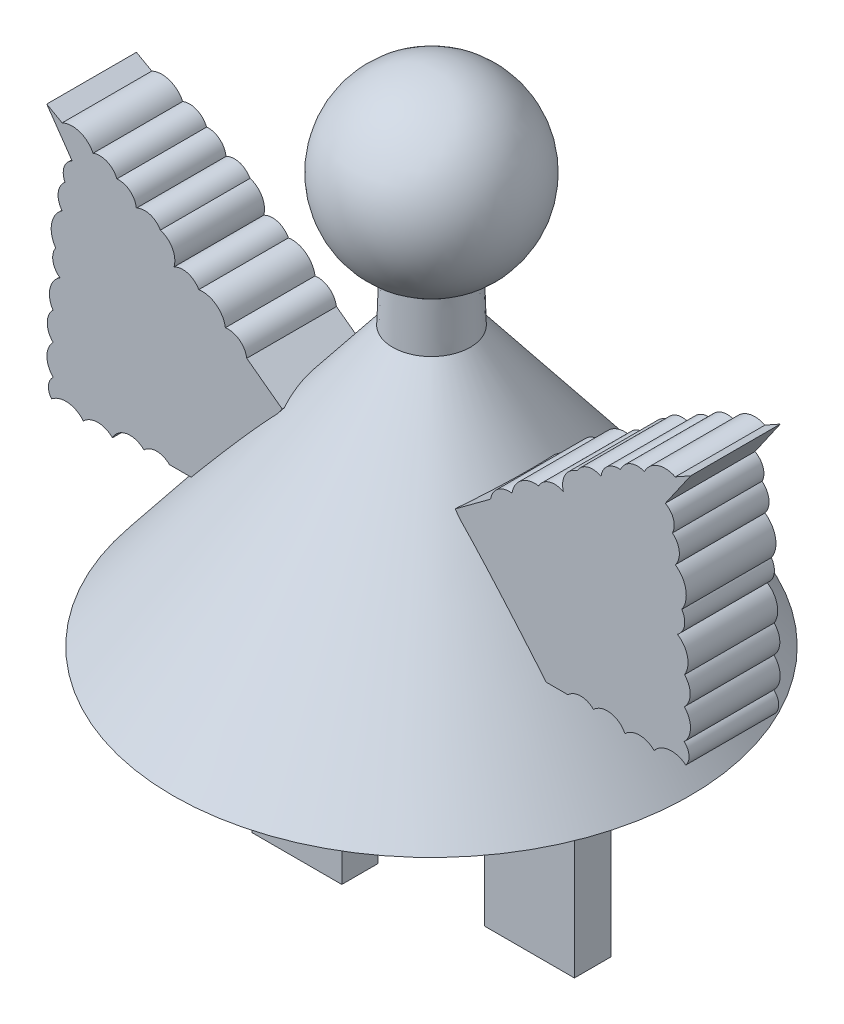
from build123d import *

# Parameters (mm, degrees)
SKETCH2_W           = 12.7
SKETCH2_H           = 5.158072601
BOSS_EXTRUDE1_DEPTH = 30.48
BOSS_EXTRUDE2_DEPTH = 6.35


with BuildPart() as part:
    # Sketch1 → Revolve1 (revolve)
    with BuildSketch(Plane.XY, mode=Mode.PRIVATE) as revolve1_sk:
        with BuildLine():
            Line((5.497877947, -31.389690294), (5.282120164, -24.249424513))
            ThreePointArc((5.282120164, -24.249424513), (12.409022752, -9.99701011), (0, 0))
            Line((0, 0), (0, -70.812800241))
            Line((0, -70.812800241), (36.63136247, -70.812800241))
            Line((36.63136247, -70.812800241), (5.497877947, -31.389690294))
        make_face()
    revolve(revolve1_sk.sketch.rotate(Axis((0, 0, 0), (0, -1, 0)), 90), axis=Axis((0, 0, 0), (0, -1, 0)))  # turned: the seam where the file's is

    # Sketch2 → Boss-Extrude1 (add)
    with BuildSketch(Plane(origin=(0, -70.812800241, 0), x_dir=(-1, 0, 0), z_dir=(0, -1, 0))):
        with Locations((13.97, -2.5009637)):
            Rectangle(SKETCH2_W, SKETCH2_H)
        with Locations((-13.97, 2.5009637)):
            Rectangle(SKETCH2_W, SKETCH2_H)
    extrude(amount=BOSS_EXTRUDE1_DEPTH)

    # Sketch4 → Boss-Extrude2 (add, symmetric)
    with BuildSketch(Plane.XY.offset(2.54)):
        with BuildLine():
            Line((23.194397658, -58.195407075), (28.218678504, -58.195407075))
            ThreePointArc((28.218678504, -58.195407075), (30.027441839, -57.44619277), (31.836205173, -58.195407075))
            ThreePointArc((31.836205173, -58.195407075), (34.251957858, -57.421245639), (36.286043383, -58.937056657))
            ThreePointArc((36.286043383, -58.937056657), (38.347997753, -58.082967192), (40.409952123, -58.937056657))
            ThreePointArc((40.409952123, -58.937056657), (42.564346856, -57.773722125), (44.910335716, -58.474507515))
            ThreePointArc((44.910335716, -58.474507515), (45.361627038, -57.049665796), (44.673222951, -55.723039401))
            ThreePointArc((44.673222951, -55.723039401), (45.573759248, -53.584134002), (44.698100059, -51.434924167))
            ThreePointArc((44.698100059, -51.434924167), (45.526766993, -49.466398887), (44.720765428, -47.488485304))
            ThreePointArc((44.720765428, -47.488485304), (45.146776163, -45.049852477), (43.723637436, -43.024243586))
            ThreePointArc((43.723637436, -43.024243586), (44.720765428, -41.476171224), (44.331188928, -39.676442795))
            ThreePointArc((44.331188928, -39.676442795), (44.916218335, -36.976008484), (43.420401182, -34.652834811))
            ThreePointArc((43.420401182, -34.652834811), (43.980987953, -32.721408857), (43.01165827, -30.959289761))
            ThreePointArc((43.01165827, -30.959289761), (43.155496077, -29.184392296), (42.002162733, -27.827641575))
            Line((42.002162733, -27.827641575), (45.598003191, -22.653559314))
            Line((45.598003191, -22.653559314), (43.420401182, -23.871865995))
            ThreePointArc((43.420401182, -23.871865995), (40.913084014, -23.73552357), (39.043734388, -25.41205589))
            ThreePointArc((39.043734388, -25.41205589), (37.052487537, -25.435932109), (35.661346423, -26.860839296))
            ThreePointArc((35.661346423, -26.860839296), (33.825367945, -27.399752632), (32.908204388, -29.079054738))
            ThreePointArc((32.908204388, -29.079054738), (31.003426578, -28.874097378), (29.511618532, -30.076051946))
            ThreePointArc((29.511618532, -30.076051946), (27.807974314, -31.448683603), (27.573913087, -33.623939136))
            ThreePointArc((27.573913087, -33.623939136), (25.608192785, -33.412424259), (24.068655026, -34.652834811))
            ThreePointArc((24.068655026, -34.652834811), (21.607314855, -35.264896302), (20.299677359, -37.438119458))
            ThreePointArc((20.299677359, -37.438119458), (18.321683781, -37.929987145), (17.270834086, -39.676442795))
            Line((17.270834086, -39.676442795), (12.250540769, -43.386453078))
            Line((12.250540769, -43.386453078), (23.194397658, -58.195407075))
        make_face()
        with BuildLine():
            Line((-23.194397658, -58.195407075), (-28.218678504, -58.195407075))
            ThreePointArc((-28.218678504, -58.195407075), (-30.027441839, -57.44619277), (-31.836205173, -58.195407075))
            ThreePointArc((-31.836205173, -58.195407075), (-34.251957858, -57.421245639), (-36.286043383, -58.937056657))
            ThreePointArc((-36.286043383, -58.937056657), (-38.347997753, -58.082967192), (-40.409952123, -58.937056657))
            ThreePointArc((-40.409952123, -58.937056657), (-42.564346856, -57.773722125), (-44.910335716, -58.474507515))
            ThreePointArc((-44.910335716, -58.474507515), (-45.361627038, -57.049665796), (-44.673222951, -55.723039401))
            ThreePointArc((-44.673222951, -55.723039401), (-45.573759248, -53.584134002), (-44.698100059, -51.434924167))
            ThreePointArc((-44.698100059, -51.434924167), (-45.526766993, -49.466398887), (-44.720765428, -47.488485304))
            ThreePointArc((-44.720765428, -47.488485304), (-45.146776163, -45.049852477), (-43.723637436, -43.024243586))
            ThreePointArc((-43.723637436, -43.024243586), (-44.720765428, -41.476171224), (-44.331188928, -39.676442795))
            ThreePointArc((-44.331188928, -39.676442795), (-44.916218335, -36.976008484), (-43.420401182, -34.652834811))
            ThreePointArc((-43.420401182, -34.652834811), (-43.980987953, -32.721408857), (-43.01165827, -30.959289761))
            ThreePointArc((-43.01165827, -30.959289761), (-43.155496077, -29.184392296), (-42.002162733, -27.827641575))
            Line((-42.002162733, -27.827641575), (-45.598003191, -22.653559314))
            Line((-45.598003191, -22.653559314), (-43.420401182, -23.871865995))
            ThreePointArc((-43.420401182, -23.871865995), (-40.913084014, -23.73552357), (-39.043734388, -25.41205589))
            ThreePointArc((-39.043734388, -25.41205589), (-37.052487537, -25.435932109), (-35.661346423, -26.860839296))
            ThreePointArc((-35.661346423, -26.860839296), (-33.825367945, -27.399752632), (-32.908204388, -29.079054738))
            ThreePointArc((-32.908204388, -29.079054738), (-31.003426578, -28.874097378), (-29.511618532, -30.076051946))
            ThreePointArc((-29.511618532, -30.076051946), (-27.807974314, -31.448683603), (-27.573913087, -33.623939136))
            ThreePointArc((-27.573913087, -33.623939136), (-25.608192785, -33.412424259), (-24.068655026, -34.652834811))
            ThreePointArc((-24.068655026, -34.652834811), (-21.607314855, -35.264896302), (-20.299677359, -37.438119458))
            ThreePointArc((-20.299677359, -37.438119458), (-18.321683781, -37.929987145), (-17.270834086, -39.676442795))
            Line((-17.270834086, -39.676442795), (-12.250540769, -43.386453078))
            Line((-12.250540769, -43.386453078), (-23.194397658, -58.195407075))
        make_face()
    extrude(amount=BOSS_EXTRUDE2_DEPTH, both=True)


solid = part.part
